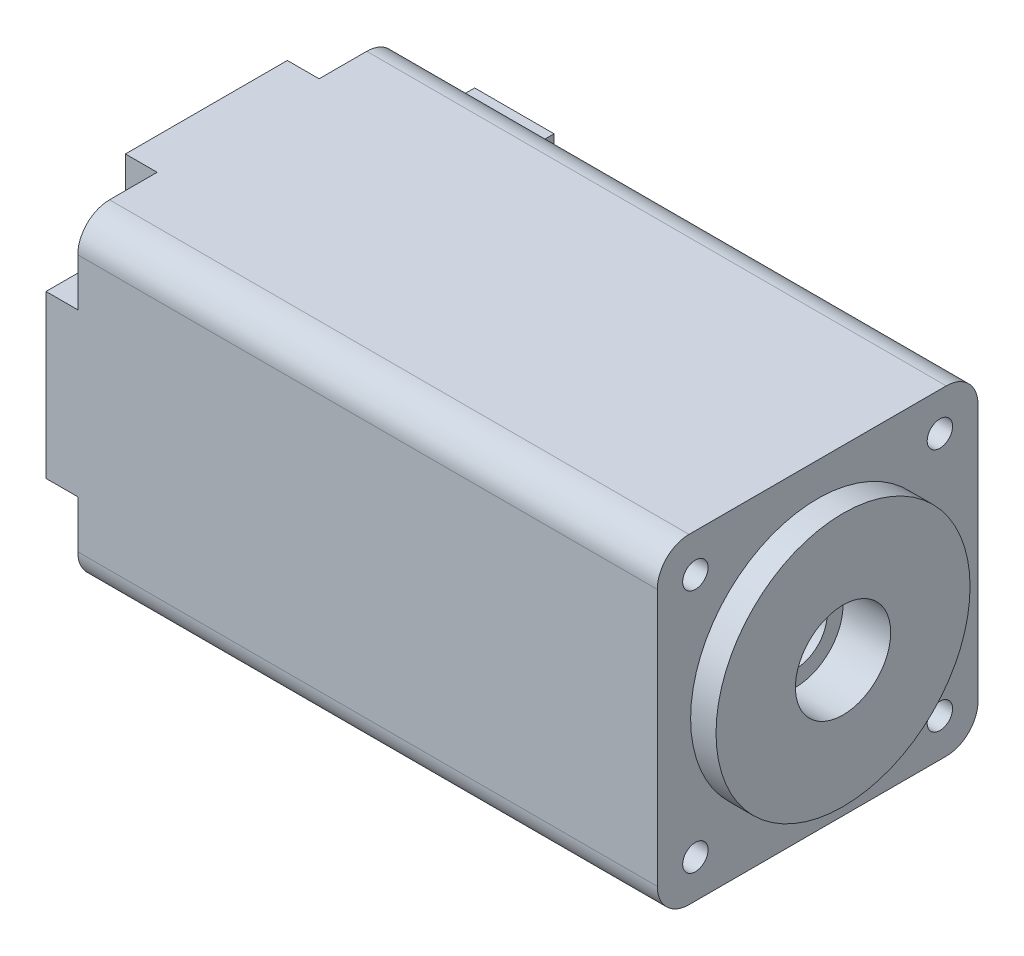
from build123d import *

# Parameters (mm, degrees)
SKETCH_1_W          = 20.2
SKETCH_1_H          = 20.2
EXTRUDE_1_DEPTH     = 38.5
SKETCH_2_R          = 8
EXTRUDE_2_DEPTH     = 1.6
CUT_EXTRUDE_1_DEPTH = 2
M2X0_41_D           = 1.6
FILLET_1_R          = 2
SKETCH_7_R          = 2
CUT_EXTRUDE_2_DEPTH = 41.1
SKETCH_8_R          = 2.65
CUT_EXTRUDE_3_DEPTH = 5.5
SKETCH_9_R          = 3
CUT_EXTRUDE_4_DEPTH = 3
SKETCH_10_W         = 5
SKETCH_10_H         = 12
EXTRUDE_3_DEPTH     = 3.5


with BuildPart() as part:
    # Эскиз1 → Бобышка-Вытянуть1 (new body)
    with BuildSketch(Plane(origin=(0, 0, 0), x_dir=(0, 0, -1), z_dir=(1, 0, 0))):
        with Locations((10.1, 10.1)):
            Rectangle(SKETCH_1_W, SKETCH_1_H)
    extrude(amount=EXTRUDE_1_DEPTH)

    # Эскиз2 → Бобышка-Вытянуть2 (add)
    with BuildSketch(Plane(origin=(38.5, 0, 0), x_dir=(0, 0, -1), z_dir=(1, 0, 0))):
        with Locations((10.1, 10.1)):
            Circle(SKETCH_2_R)
    extrude(amount=EXTRUDE_2_DEPTH)

    # Эскиз3 → Вырез-Вытянуть1 (cut)
    with BuildSketch(Plane.ZY):
        with BuildLine():
            Line((-5, 20.2), (-5, 18.2))
            ThreePointArc((-5, 18.2), (-4.121320344, 16.078679656), (-2, 15.2))
            Line((-2, 15.2), (0, 15.2))
            Line((0, 15.2), (0, 20.2))
            Line((0, 20.2), (-5, 20.2))
        make_face()
        with BuildLine():
            Line((-20.2, 20.2), (-15.2, 20.2))
            Line((-15.2, 20.2), (-15.2, 18.2))
            ThreePointArc((-15.2, 18.2), (-16.078679656, 16.078679656), (-18.2, 15.2))
            Line((-18.2, 15.2), (-20.2, 15.2))
            Line((-20.2, 15.2), (-20.2, 20.2))
        make_face()
        with BuildLine():
            Line((0, 0), (-5, 0))
            Line((-5, 0), (-5, 2))
            ThreePointArc((-5, 2), (-4.121320344, 4.121320344), (-2, 5))
            Line((-2, 5), (0, 5))
            Line((0, 5), (0, 0))
        make_face()
        with BuildLine():
            Line((-15.2, 0), (-15.2, 2))
            ThreePointArc((-15.2, 2), (-16.078679656, 4.121320344), (-18.2, 5))
            Line((-18.2, 5), (-20.2, 5))
            Line((-20.2, 5), (-20.2, 0))
            Line((-20.2, 0), (-15.2, 0))
        make_face()
    extrude(amount=-CUT_EXTRUDE_1_DEPTH, mode=Mode.SUBTRACT)

    # Отверстие обработанное метчиком M2x0.41 (through all)
    with Locations(Plane.ZY.offset(-2)):
        with Locations((-17.8, 17.8), (-2.4, 17.8), (-2.4, 2.4), (-17.8, 2.4)):
            Hole(M2X0_41_D / 2)

    # Скругление1
    fillet_1_edges = [part.edges().sort_by_distance(p)[0] for p in [
        (20.25, 20.2, 0),
        (20.25, 20.2, -20.2),
        (20.25, 0, -20.2),
        (20.25, 0, 0),
    ]]
    fillet(fillet_1_edges, radius=FILLET_1_R)

    # Эскиз7 → Вырез-Вытянуть2 (cut, through all)
    with BuildSketch(Plane(origin=(40.1, 0, 0), x_dir=(0, 0, -1), z_dir=(1, 0, 0))):
        with Locations((10.1, 10.1)):
            Circle(SKETCH_7_R)
    extrude(amount=-CUT_EXTRUDE_2_DEPTH, mode=Mode.SUBTRACT)

    # Эскиз8 → Вырез-Вытянуть3 (cut)
    with BuildSketch(Plane.ZY):
        with Locations((-10.1, 10.1)):
            Circle(SKETCH_8_R)
    extrude(amount=-CUT_EXTRUDE_3_DEPTH, mode=Mode.SUBTRACT)

    # Эскиз9 → Вырез-Вытянуть4 (cut)
    with BuildSketch(Plane(origin=(40.1, 0, 0), x_dir=(0, 0, -1), z_dir=(1, 0, 0))):
        with Locations((10.1, 10.1)):
            Circle(SKETCH_9_R)
    extrude(amount=-CUT_EXTRUDE_4_DEPTH, mode=Mode.SUBTRACT)

    # Эскиз10 → Бобышка-Вытянуть3 (add)
    with BuildSketch(Plane(origin=(0, 0, -20.2), x_dir=(-1, 0, 0), z_dir=(0, 0, -1))):
        with Locations((-5.8, 10.1)):
            Rectangle(SKETCH_10_W, SKETCH_10_H)
    extrude(amount=EXTRUDE_3_DEPTH)


solid = part.part
